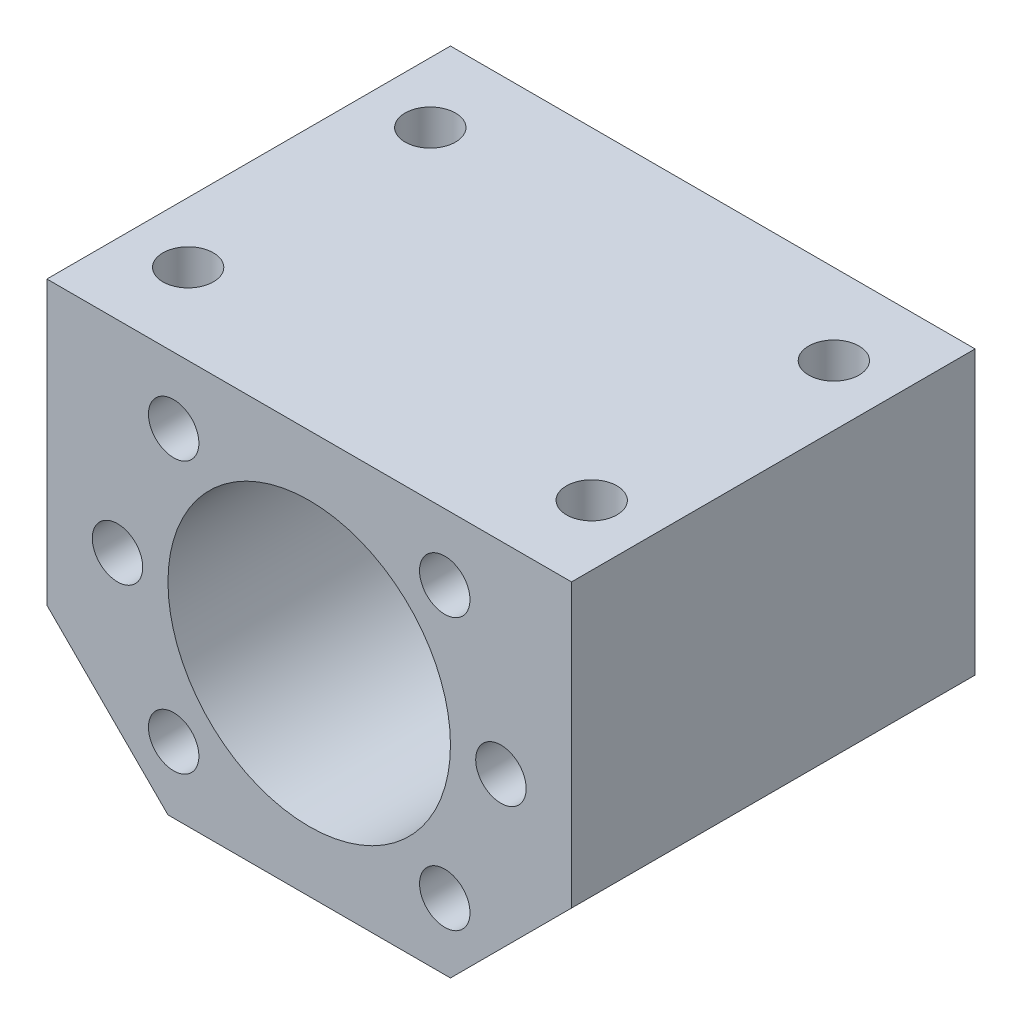
from build123d import *

# Parameters (mm, degrees)
SKETCH_1_R          = 14
SKETCH_1_R_2        = 2.5
EXTRUDE_1_DEPTH     = 40
SKETCH_3_R          = 2.5
CUT_EXTRUDE_1_DEPTH = 10


with BuildPart() as part:
    # 草图1 → 凸台-拉伸1 (new body)
    with BuildSketch(Plane.XY):
        Polygon((26, 20), (-26, 20), (-26, -8), (-14, -20), (14, -20), (26, -8), align=None)
        Circle(SKETCH_1_R, mode=Mode.SUBTRACT)
        with Locations((-19, 0)):
            Circle(SKETCH_1_R_2, mode=Mode.SUBTRACT)
        with Locations((-13.435028843, 13.435028843)):
            Circle(SKETCH_1_R_2, mode=Mode.SUBTRACT)
        with Locations((-13.435028843, -13.435028843)):
            Circle(SKETCH_1_R_2, mode=Mode.SUBTRACT)
        with Locations((13.435028843, -13.435028843)):
            Circle(SKETCH_1_R_2, mode=Mode.SUBTRACT)
        with Locations((13.435028843, 13.435028843)):
            Circle(SKETCH_1_R_2, mode=Mode.SUBTRACT)
        with Locations((19, 0)):
            Circle(SKETCH_1_R_2, mode=Mode.SUBTRACT)
    extrude(amount=EXTRUDE_1_DEPTH)

    # 草图3 → 切除-拉伸1 (cut)
    with BuildSketch(Plane(origin=(0, 20, 0), x_dir=(1, 0, 0), z_dir=(0, 1, 0))):
        with Locations((-20, -8)):
            Circle(SKETCH_3_R)
        with Locations((-20, -32)):
            Circle(SKETCH_3_R)
        with Locations((20, -32)):
            Circle(SKETCH_3_R)
        with Locations((20, -8)):
            Circle(SKETCH_3_R)
    extrude(amount=-CUT_EXTRUDE_1_DEPTH, mode=Mode.SUBTRACT)


solid = part.part
